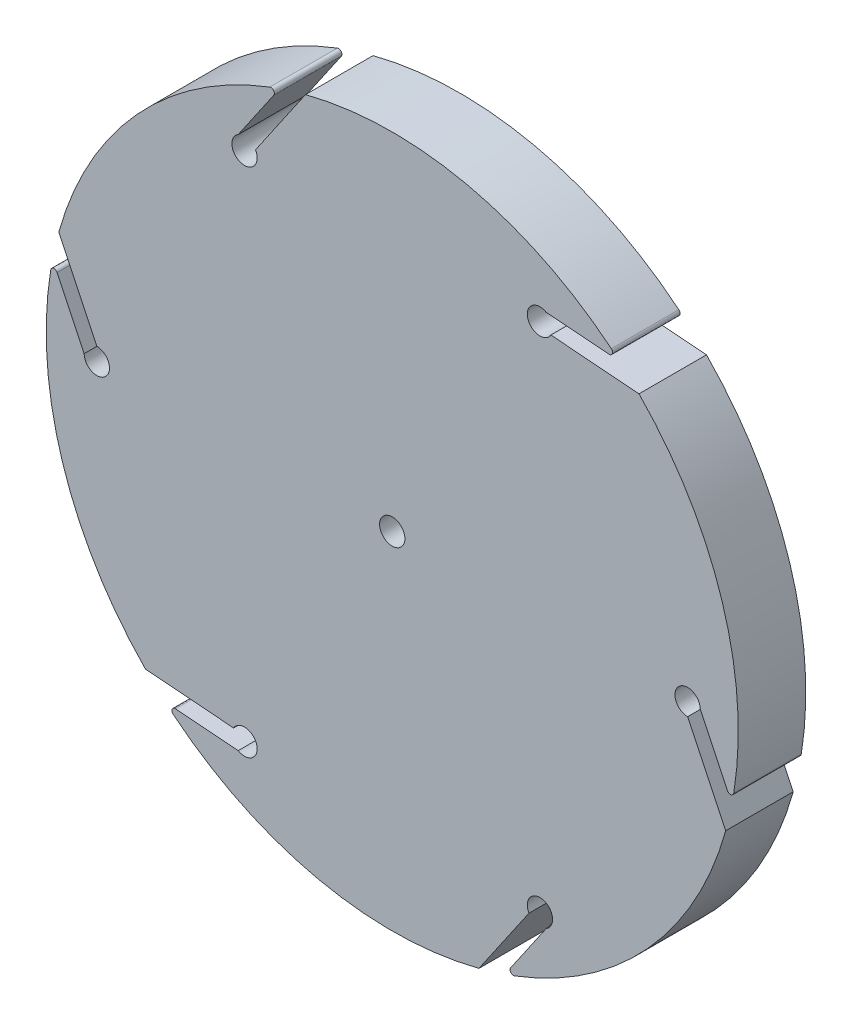
from build123d import *

# Parameters (mm, degrees)
MODEL_R                        = 20.5
MODEL_R_2                      = 0.75
MAIN_DIFFERENTIAL_DISK_DEPTH   = 4
TENDON_HOLDER_DEPTH            = 5
DIFFERENTIAL_DISK_CONTOURING_R = 0.2


with BuildPart() as part:
    # Model → Main Differential Disk (new body)
    with BuildSketch(Plane.XY):
        Circle(MODEL_R)
        with Locations((-8.75, 15.155444566)):
            Circle(MODEL_R_2, mode=Mode.SUBTRACT)
        with Locations((8.75, 15.155444566)):
            Circle(MODEL_R_2, mode=Mode.SUBTRACT)
        with Locations((17.5, 0)):
            Circle(MODEL_R_2, mode=Mode.SUBTRACT)
        with Locations((8.75, -15.155444566)):
            Circle(MODEL_R_2, mode=Mode.SUBTRACT)
        with Locations((-8.75, -15.155444566)):
            Circle(MODEL_R_2, mode=Mode.SUBTRACT)
        Circle(MODEL_R_2, mode=Mode.SUBTRACT)
        with Locations((-17.5, 0)):
            Circle(MODEL_R_2, mode=Mode.SUBTRACT)
    extrude(amount=MAIN_DIFFERENTIAL_DISK_DEPTH)

    # Sketch1 → Tendon Holder (cut, through all)
    with BuildSketch(Plane.XY.offset(4)):
        with BuildLine():
            Line((-18.25, 0), (-20.121847663, 3.919342625))
            ThreePointArc((-20.121847663, 3.919342625), (-19.953970316, 4.699900916), (-19.755825892, 5.473330187))
            Line((-19.755825892, 5.473330187), (-17.5, 0.75))
            ThreePointArc((-17.5, 0.75), (-16.969669914, -0.530330086), (-18.25, 0))
        make_face()
        with BuildLine():
            Line((-9.125, 15.804963619), (-6.666673552, 19.38570256))
            ThreePointArc((-6.666673552, 19.38570256), (-5.906751569, 19.630595658), (-5.137869961, 19.845712188))
            Line((-5.137869961, 19.845712188), (-8.100480947, 15.530444566))
            ThreePointArc((-8.100480947, 15.530444566), (-8.944114284, 14.431000197), (-9.125, 15.804963619))
        make_face()
        with BuildLine():
            Line((9.125, 15.804963619), (13.455174111, 15.466359935))
            ThreePointArc((13.455174111, 15.466359935), (14.047218747, 14.930694742), (14.617955931, 14.372382002))
            Line((14.617955931, 14.372382002), (9.399519053, 14.780444566))
            ThreePointArc((9.399519053, 14.780444566), (8.02555563, 14.961330282), (9.125, 15.804963619))
        make_face()
        with BuildLine():
            Line((18.25, 0), (20.121847663, -3.919342625))
            ThreePointArc((20.121847663, -3.919342625), (19.953970316, -4.699900916), (19.755825892, -5.473330187))
            Line((19.755825892, -5.473330187), (17.5, -0.75))
            ThreePointArc((17.5, -0.75), (16.969669914, 0.530330086), (18.25, 0))
        make_face()
        with BuildLine():
            Line((9.125, -15.804963619), (6.666673552, -19.38570256))
            ThreePointArc((6.666673552, -19.38570256), (5.906751569, -19.630595658), (5.137869961, -19.845712188))
            Line((5.137869961, -19.845712188), (8.100480947, -15.530444566))
            ThreePointArc((8.100480947, -15.530444566), (8.944114284, -14.431000197), (9.125, -15.804963619))
        make_face()
        with BuildLine():
            Line((-9.125, -15.804963619), (-13.455174111, -15.466359935))
            ThreePointArc((-13.455174111, -15.466359935), (-14.047218747, -14.930694742), (-14.617955931, -14.372382002))
            Line((-14.617955931, -14.372382002), (-9.399519053, -14.780444566))
            ThreePointArc((-9.399519053, -14.780444566), (-8.02555563, -14.961330282), (-9.125, -15.804963619))
        make_face()
    extrude(amount=-TENDON_HOLDER_DEPTH, mode=Mode.SUBTRACT)

    # Differential Disk Contouring
    differential_disk_contouring_edges = [part.edges().sort_by_distance(p)[0] for p in [
        (6.666673552, -19.38570256, 2),
        (-13.455174111, -15.466359935, 2),
        (-20.121847663, 3.919342625, 2),
        (-6.666673552, 19.38570256, 2),
        (13.455174111, 15.466359935, 2),
        (20.121847663, -3.919342625, 2),
    ]]
    fillet(differential_disk_contouring_edges, radius=DIFFERENTIAL_DISK_CONTOURING_R)


solid = part.part
